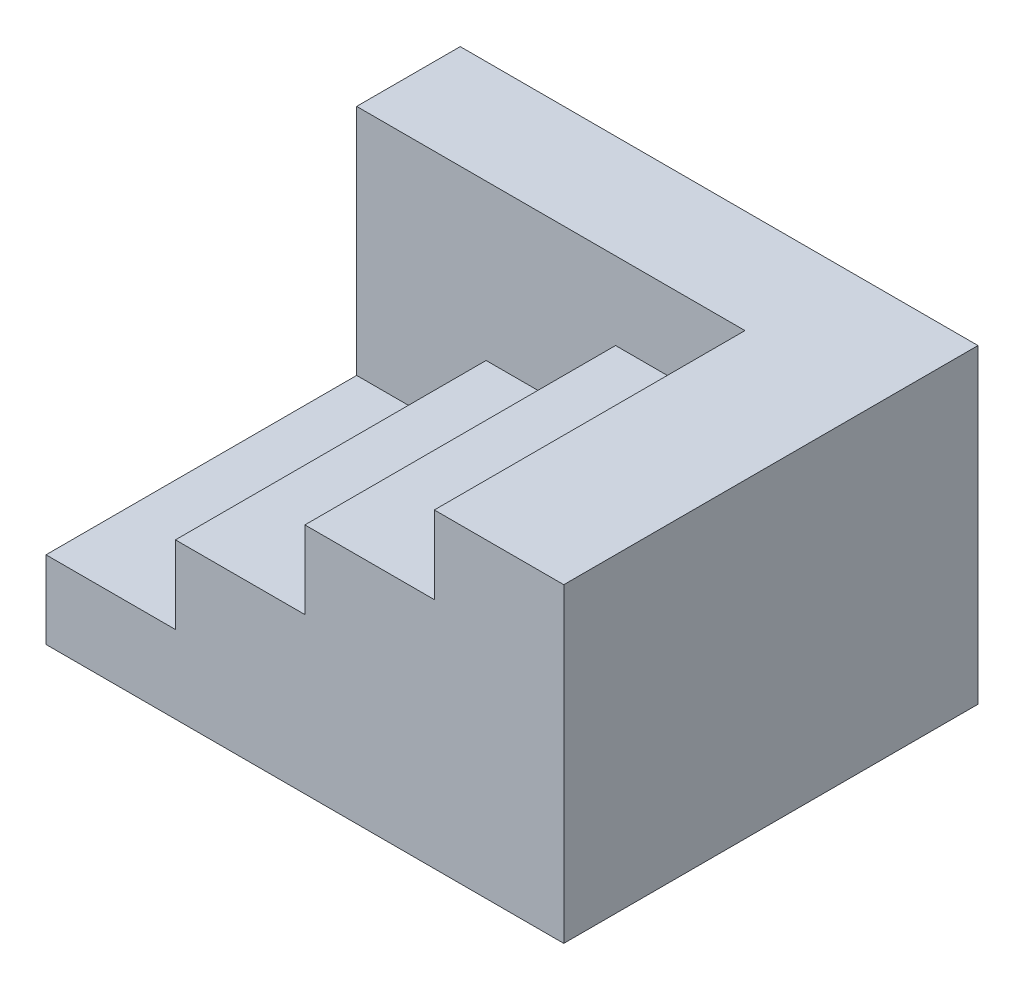
from build123d import *

# Parameters (mm, degrees)
SKETCH1_W           = 100
SKETCH1_H           = 80
BOSS_EXTRUDE1_DEPTH = 60
CUT_EXTRUDE1_DEPTH  = 60


with BuildPart() as part:
    # Sketch1 → Boss-Extrude1 (new body)
    with BuildSketch(Plane(origin=(0, 0, 0), x_dir=(1, 0, 0), z_dir=(0, 1, 0))):
        Rectangle(SKETCH1_W, SKETCH1_H)
    extrude(amount=BOSS_EXTRUDE1_DEPTH)

    # Sketch2 → Cut-Extrude1 (cut)
    with BuildSketch(Plane.XY.offset(40)):
        Polygon((-50, 60), (25, 60), (25, 45), (0, 45), (0, 30), (-25, 30), (-25, 15), (-50, 15), align=None)
    extrude(amount=-CUT_EXTRUDE1_DEPTH, mode=Mode.SUBTRACT)


solid = part.part
